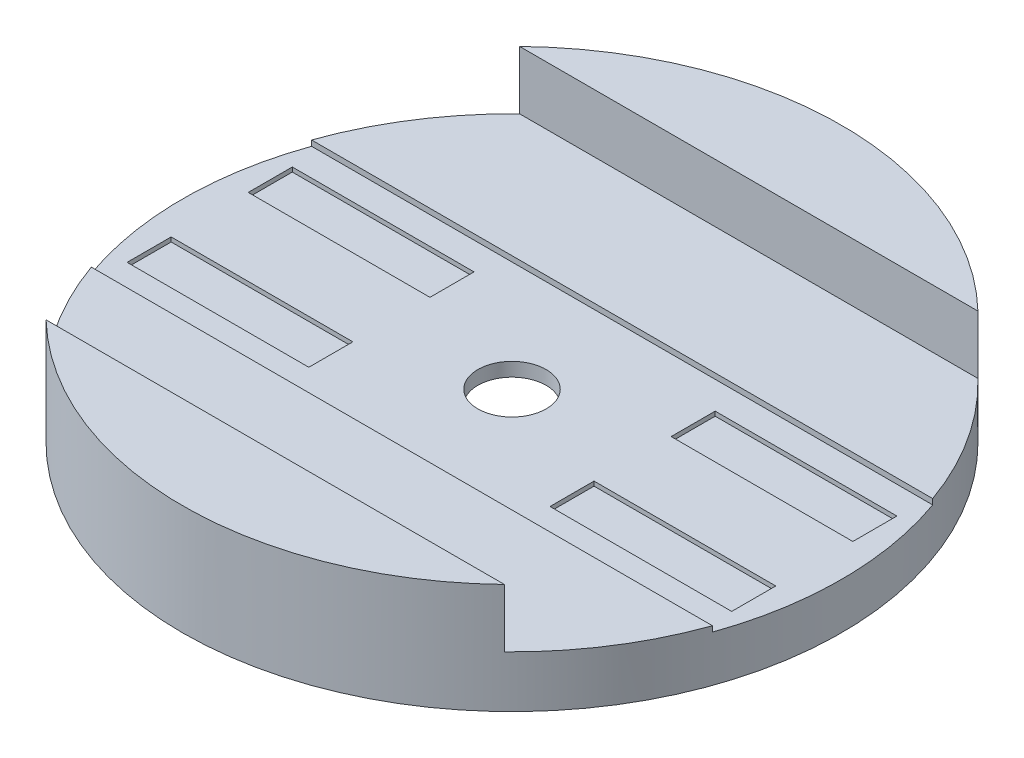
from build123d import *

# Parameters (mm, degrees)
SKETCH1_R           = 76
BOSS_EXTRUDE1_DEPTH = 25.4
CUT_EXTRUDE4_DEPTH  = 13.462
SKETCH5_R           = 7.874
CUT_EXTRUDE5_DEPTH  = 20
SKETCH13_R          = 70
CUT_EXTRUDE9_DEPTH  = 7.5
CUT_EXTRUDE11_DEPTH = 1.27
SKETCH16_W          = 41.91
SKETCH16_H          = 10.16
CUT_EXTRUDE12_DEPTH = 1.016


with BuildPart() as part:
    # Sketch1 → Boss-Extrude1 (new body)
    with BuildSketch(Plane(origin=(0, 0, 0), x_dir=(1, 0, 0), z_dir=(0, 1, 0))):
        Circle(SKETCH1_R)
    extrude(amount=BOSS_EXTRUDE1_DEPTH)

    # Sketch2 → Cut-Extrude4 (cut)
    with BuildSketch(Plane(origin=(0, 25.4, 0), x_dir=(1, 0, 0), z_dir=(0, 1, 0))):
        with BuildLine():
            Line((-58.007955522, 54.61), (58.007955522, 54.61))
            ThreePointArc((58.007955522, 54.61), (112.617955522, 0), (58.007955522, -54.61))
            Line((58.007955522, -54.61), (-58.007955522, -54.61))
            ThreePointArc((-58.007955522, -54.61), (-112.617955522, 0), (-58.007955522, 54.61))
        make_face()
    extrude(amount=-CUT_EXTRUDE4_DEPTH, mode=Mode.SUBTRACT)

    # Sketch5 → Cut-Extrude5 (cut)
    with BuildSketch(Plane(origin=(0, 11.938, 0), x_dir=(1, 0, 0), z_dir=(0, 1, 0))):
        Circle(SKETCH5_R)
    extrude(amount=-CUT_EXTRUDE5_DEPTH, mode=Mode.SUBTRACT)

    # Sketch13 → Cut-Extrude9 (cut)
    with BuildSketch(Plane(origin=(0, 0, 0), x_dir=(-1, 0, 0), z_dir=(0, -1, 0))):
        Circle(SKETCH13_R)
    extrude(amount=-CUT_EXTRUDE9_DEPTH, mode=Mode.SUBTRACT)

    # Sketch15 → Cut-Extrude11 (cut)
    with BuildSketch(Plane(origin=(0, 11.938, 0), x_dir=(1, 0, 0), z_dir=(0, 1, 0))):
        with BuildLine():
            Line((76, -25.4), (-76, -25.4))
            ThreePointArc((-76, -25.4), (-101.4, 0), (-76, 25.4))
            Line((-76, 25.4), (76, 25.4))
            ThreePointArc((76, 25.4), (101.4, 0), (76, -25.4))
        make_face()
    extrude(amount=-CUT_EXTRUDE11_DEPTH, mode=Mode.SUBTRACT)

    # Sketch16 → Cut-Extrude12 (cut)
    with BuildSketch(Plane(origin=(0, 10.668, 0), x_dir=(1, 0, 0), z_dir=(0, 1, 0))):
        with Locations((-48.768, -13.97)):
            Rectangle(SKETCH16_W, SKETCH16_H)
        with Locations((-48.768, 13.97)):
            Rectangle(SKETCH16_W, SKETCH16_H)
        with Locations((48.768, -13.97)):
            Rectangle(SKETCH16_W, SKETCH16_H)
        with Locations((48.768, 13.97)):
            Rectangle(SKETCH16_W, SKETCH16_H)
    extrude(amount=-CUT_EXTRUDE12_DEPTH, mode=Mode.SUBTRACT)


solid = part.part
